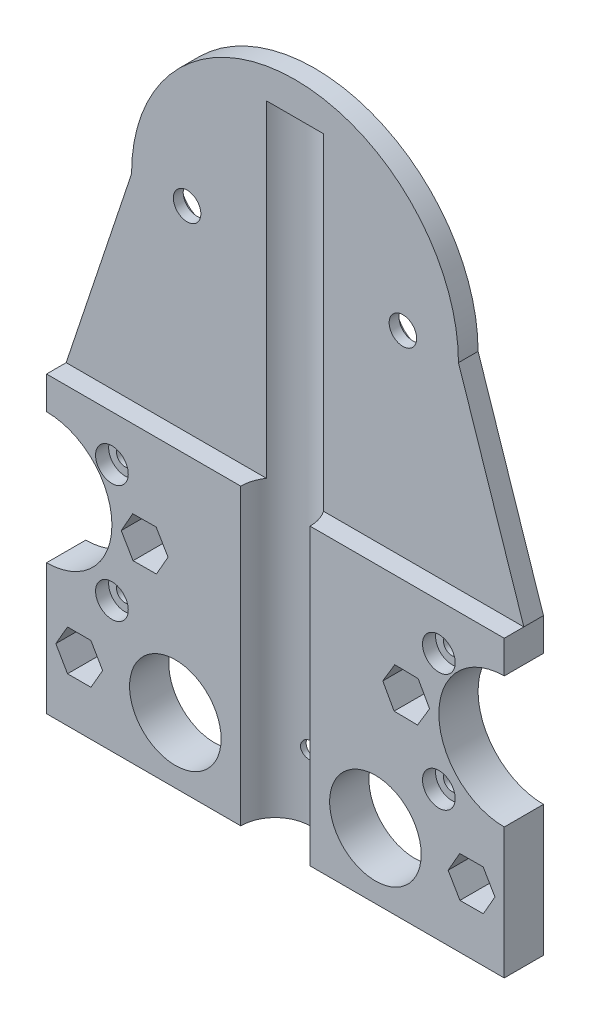
from build123d import *

# Parameters (mm, degrees)
SKETCH_1_R           = 1.3
EXTRUDE_1_DEPTH      = 6
SKETCH_1_3_R         = 2.1
EXTRUDE_2_DEPTH      = 3
SKETCH_3_R           = 5.3
CUT_EXTRUDE_1_DEPTH  = 95
SKETCH_6_R           = 3.2
SKETCH_6_R_2         = 3
CUT_EXTRUDE_3_DEPTH  = 2
SKETCH_9_R           = 4
CUT_EXTRUDE_6_DEPTH  = 1.5
CUT_EXTRUDE_7_DEPTH  = 106.990565621
CUT_EXTRUDE_8_DEPTH  = 107.117859012
SKETCH_12_R          = 7
CUT_EXTRUDE_9_DEPTH  = 107.117859012
SKETCH_13_R          = 2.5
CUT_EXTRUDE_11_DEPTH = 2


with BuildPart() as part:
    # 草图1 → 凸台-拉伸1 (new body)
    with BuildSketch(Plane.XY):
        Polygon((-35, 0), (0, 0), (35, 0), (35, 45), (0, 45), (-35, 45), align=None)
        Polygon((-26.420428959, 10.002120735), (-28.208377869, 6.901060912), (-31.78794891, 6.898940176), (-33.579571041, 9.997879265), (-31.791622131, 13.098939088), (-28.21205109, 13.101059824), align=None, mode=Mode.SUBTRACT)
        with Locations((-25, 20)):
            Circle(SKETCH_1_R, mode=Mode.SUBTRACT)
        Polygon((-16.420523373, 30.026084728), (-18.187671649, 26.913124673), (-21.767148276, 26.887039945), (-23.579476627, 29.973915272), (-21.812328351, 33.086875327), (-18.232851724, 33.112960055), align=None, mode=Mode.SUBTRACT)
        with Locations((-25, 38)):
            Circle(SKETCH_1_R, mode=Mode.SUBTRACT)
        with Locations((0, 10)):
            Circle(SKETCH_1_R, mode=Mode.SUBTRACT)
        Polygon((33.579530154, 10.017239862), (31.804695235, 6.908655884), (28.225165081, 6.891416023), (26.420469846, 9.982760138), (28.195304765, 13.091344116), (31.774834919, 13.108583977), align=None, mode=Mode.SUBTRACT)
        with Locations((25, 20)):
            Circle(SKETCH_1_R, mode=Mode.SUBTRACT)
        Polygon((23.579135684, 29.944133288), (21.74118585, 26.872444218), (18.162050166, 26.92831093), (16.420864316, 30.055866712), (18.25881415, 33.127555782), (21.837949834, 33.07168907), align=None, mode=Mode.SUBTRACT)
        with Locations((25, 38)):
            Circle(SKETCH_1_R, mode=Mode.SUBTRACT)
    extrude(amount=EXTRUDE_1_DEPTH)

    # 草图1<3> → 凸台-拉伸2 (add)
    with BuildSketch(Plane.XY):
        Polygon((0, 45), (35, 45), (35, 100), (-35, 100), (-35, 45), align=None)
        with Locations((-16.5, 75)):
            Circle(SKETCH_1_3_R, mode=Mode.SUBTRACT)
        with Locations((16.5, 75)):
            Circle(SKETCH_1_3_R, mode=Mode.SUBTRACT)
    extrude(amount=EXTRUDE_2_DEPTH)

    # 草图3 → 切除-拉伸1 (cut)
    with BuildSketch(Plane(origin=(0, 0, 0), x_dir=(-1, 0, 0), z_dir=(0, -1, 0))):
        with Locations((0, -6)):
            Circle(SKETCH_3_R)
    extrude(amount=-CUT_EXTRUDE_1_DEPTH, mode=Mode.SUBTRACT)

    # 草图6 → 切除-拉伸3 (cut)
    with BuildSketch(Plane(origin=(0, 0, 0), x_dir=(-1, 0, 0), z_dir=(0, 0, -1))):
        with Locations((25, 38)):
            Circle(SKETCH_6_R)
        with Locations((25, 20)):
            Circle(SKETCH_6_R)
        with Locations((-25, 20)):
            Circle(SKETCH_6_R)
        with Locations((-25, 38)):
            Circle(SKETCH_6_R_2)
    extrude(amount=-CUT_EXTRUDE_3_DEPTH, mode=Mode.SUBTRACT)

    # 草图9 → 切除-拉伸6 (cut)
    with BuildSketch(Plane(origin=(0, 0, 0), x_dir=(-1, 0, 0), z_dir=(0, 0, -1))):
        with Locations((-16.5, 75)):
            Circle(SKETCH_9_R)
        with Locations((16.5, 75)):
            Circle(SKETCH_9_R)
    extrude(amount=-CUT_EXTRUDE_6_DEPTH, mode=Mode.SUBTRACT)

    # 草图10 → 切除-拉伸7 (cut, through all)
    with BuildSketch(Plane.XY.offset(3)):
        with BuildLine():
            Line((35, 100), (0, 100))
            ThreePointArc((0, 100), (17.67766953, 92.67766953), (25, 75))
            Line((25, 75), (35, 45))
            Line((35, 45), (35, 100))
        make_face()
        with BuildLine():
            Line((-35, 45), (-25, 75))
            ThreePointArc((-25, 75), (-17.67766953, 92.67766953), (0, 100))
            Line((0, 100), (-35, 100))
            Line((-35, 100), (-35, 45))
        make_face()
    extrude(amount=-CUT_EXTRUDE_7_DEPTH, mode=Mode.SUBTRACT)

    # 草图11 → 切除-拉伸8 (cut, through all)
    with BuildSketch(Plane.XY.offset(6)):
        with BuildLine():
            ThreePointArc((-35, 20), (-25, 30), (-35, 40))
            Line((-35, 40), (-35, 20))
        make_face()
        with BuildLine():
            Line((35, 20), (35, 40))
            ThreePointArc((35, 40), (25, 30), (35, 20))
        make_face()
    extrude(amount=-CUT_EXTRUDE_8_DEPTH, mode=Mode.SUBTRACT)

    # 草图12 → 切除-拉伸9 (cut, through all)
    with BuildSketch(Plane.XY.offset(6)):
        with Locations((-15.3, 10)):
            Circle(SKETCH_12_R)
        with Locations((15.3, 10)):
            Circle(SKETCH_12_R)
    extrude(amount=-CUT_EXTRUDE_9_DEPTH, mode=Mode.SUBTRACT)

    # 草图13 → 切除-拉伸11 (cut)
    with BuildSketch(Plane.XY.offset(6)):
        with Locations((-25, 20)):
            Circle(SKETCH_13_R)
        with Locations((25, 20)):
            Circle(SKETCH_13_R)
        with Locations((25, 38)):
            Circle(SKETCH_13_R)
        with Locations((-25, 38)):
            Circle(SKETCH_13_R)
    extrude(amount=-CUT_EXTRUDE_11_DEPTH, mode=Mode.SUBTRACT)


solid = part.part
